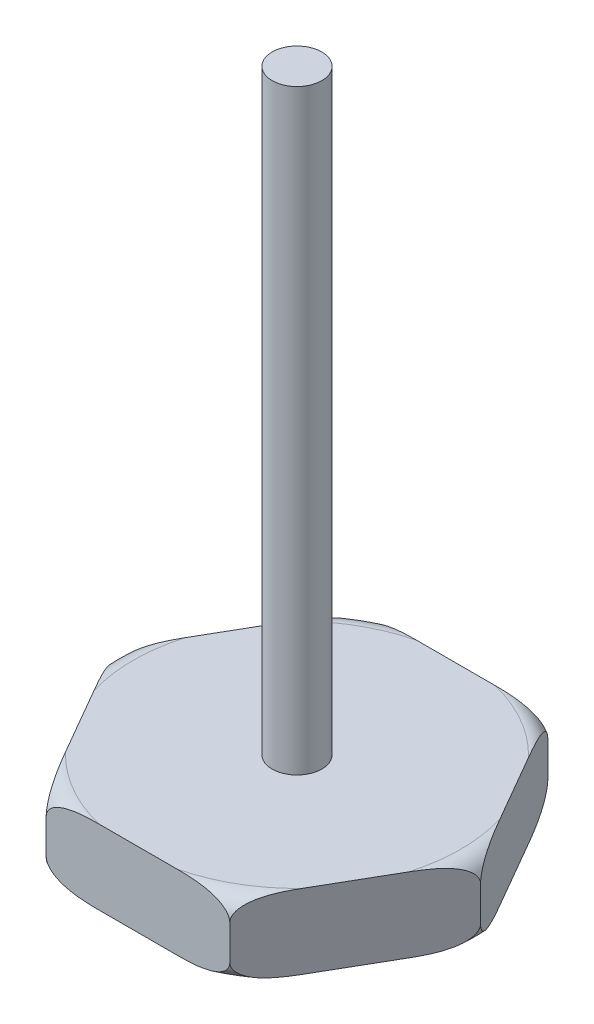
from build123d import *

# Parameters (mm, degrees)
BOSS_EXTRUDE1_DEPTH = 3.75
SKETCH4_R           = 1.25
BOSS_EXTRUDE2_DEPTH = 30


with BuildPart() as part:
    # Sketch1 → Boss-Extrude1 (new body)
    with BuildSketch(Plane(origin=(0, 0, 0), x_dir=(1, 0, 0), z_dir=(0, 1, 0))):
        Polygon((9.237604307, 0), (4.618802154, 8), (-4.618802154, 8), (-9.237604307, 0), (-4.618802154, -8), (4.618802154, -8), align=None)
    extrude(amount=BOSS_EXTRUDE1_DEPTH)

    # Sketch2 → Cut-Revolve1 (revolve, cut)
    with BuildSketch(Plane.XY):
        with BuildLine():
            Line((9.237604307, 2.75), (9.237604307, 3.75))
            Line((9.237604307, 3.75), (8.237604307, 3.75))
            ThreePointArc((8.237604307, 3.75), (8.944711088, 3.457106781), (9.237604307, 2.75))
        make_face()
    revolve(axis=Axis((0, 0, 0), (0, 1, 0)), mode=Mode.SUBTRACT)

    # Sketch3 → Cut-Revolve2 (revolve, cut)
    with BuildSketch(Plane.XY):
        with BuildLine():
            Line((9.237604307, 0), (8.237604307, 0))
            ThreePointArc((8.237604307, 0), (8.944711088, 0.292893219), (9.237604307, 1))
            Line((9.237604307, 1), (9.237604307, 0))
        make_face()
    revolve(axis=Axis((0, 0, 0), (0, 1, 0)), mode=Mode.SUBTRACT)

    # Sketch4 → Boss-Extrude2 (add)
    with BuildSketch(Plane(origin=(0, 3.75, 0), x_dir=(1, 0, 0), z_dir=(0, 1, 0))):
        Circle(SKETCH4_R)
    extrude(amount=BOSS_EXTRUDE2_DEPTH)


solid = part.part
